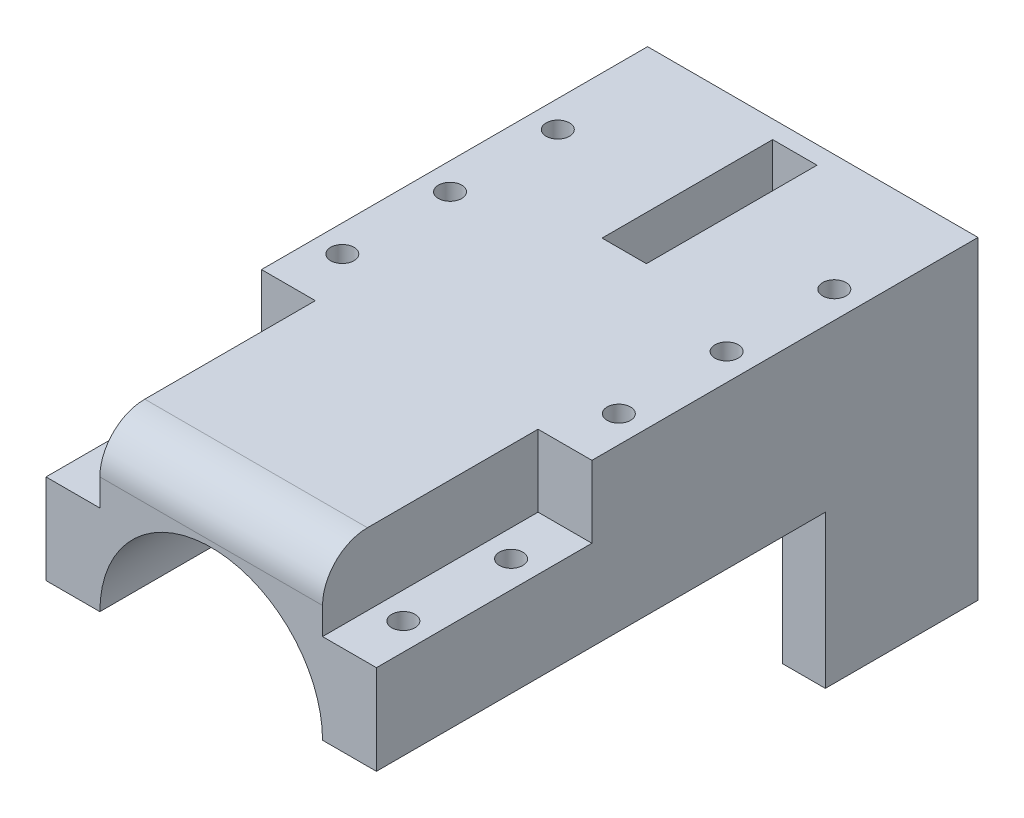
from build123d import *

# Parameters (mm, degrees)
BOSS_EXTRU_1_DEPTH       = 132
ESQUISSE3_W              = 4.94012132
ESQUISSE3_H              = 40
ENL_V_MAT_EXTRU_2_DEPTH  = 9
ESQUISSE4_R              = 1.3
ENL_V_MAT_EXTRU_3_DEPTH  = 18
ESQUISSE5_W              = 6
ESQUISSE5_H              = 24
ENL_V_MAT_EXTRU_4_DEPTH  = 8
BOSS_EXTRU_2_REACH       = 38.8
ESQUISSE7_W              = 2
ESQUISSE7_H              = 18
ENL_V_MAT_EXTRU_5_DEPTH  = 15
ENL_V_MAT_EXTRU_6_DEPTH  = 15
ESQUISSE10_W             = 5.625
ESQUISSE10_H             = 32
BOSS_EXTRU_3_DEPTH       = 17
ESQUISSE14_W             = 11.349962924
ESQUISSE14_H             = 7.588006138
BOSS_EXTRU_5_DEPTH       = 6
ESQUISSE16_W             = 13.258712606
ESQUISSE16_H             = 4.272246905
ENL_V_MAT_EXTRU_7_DEPTH  = 11
ESQUISSE17_W             = 15.613345165
ESQUISSE17_H             = 5.100882875
BOSS_EXTRU_6_DEPTH       = 11
BOSS_EXTRU_6_DEPTH_BACK  = 11
ESQUISSE11_R             = 1.85
ESQUISSE11_R_2           = 1.3
ESQUISSE11_R_3           = 2.916438904
ENL_V_MAT_EXTRU_8_DEPTH  = 8
ESQUISSE18_W             = 9.677736186
ESQUISSE18_H             = 8.253244783
ENL_V_MAT_EXTRU_9_DEPTH  = 10
CONG_2_R                 = 5
ESQUISSE20_W             = 27.3
ESQUISSE20_H             = 40.032665724
ENL_V_MAT_EXTRU_11_DEPTH = 22
ESQUISSE22_R             = 2.780350547
ENL_V_MAT_EXTRU_12_DEPTH = 33
ENL_V_MAT_EXTRU_13_DEPTH = 23
ESQUISSE24_W             = 101.568694303
ESQUISSE24_H             = 64.896510992
ENL_V_MAT_EXTRU_14_DEPTH = 80


with BuildPart() as part:
    # Esquisse1 → Boss.-Extru.1 (new body)
    with BuildSketch(Plane.XY):
        with BuildLine():
            Line((-12.4, 0), (-18.4, 0))
            Line((-18.4, 0), (-18.4, 18))
            Line((-18.4, 18), (18.4, 18))
            Line((18.4, 18), (18.4, 0))
            Line((18.4, 0), (12.4, 0))
            ThreePointArc((12.4, 0), (0, 12.4), (-12.4, 0))
        make_face()
    extrude(amount=BOSS_EXTRU_1_DEPTH)

    # Esquisse3 → Enlèv. mat.-Extru.2 (cut)
    with BuildSketch(Plane.XZ.offset(-18)):
        with Locations((0, 66)):
            Rectangle(ESQUISSE3_W, ESQUISSE3_H)
    extrude(amount=ENL_V_MAT_EXTRU_2_DEPTH, mode=Mode.SUBTRACT)

    # Esquisse4 → Enlèv. mat.-Extru.3 (cut)
    with BuildSketch(Plane(origin=(0, 18, 0), x_dir=(1, 0, 0), z_dir=(0, 1, 0))):
        with Locations((15.4, -6)):
            Circle(ESQUISSE4_R)
        with Locations((15.4, -18)):
            Circle(ESQUISSE4_R)
        with Locations((-15.4, -6)):
            Circle(ESQUISSE4_R)
        with Locations((-15.4, -18)):
            Circle(ESQUISSE4_R)
        with Locations((15.4, -30)):
            Circle(ESQUISSE4_R)
        with Locations((-15.4, -30)):
            Circle(ESQUISSE4_R)
        with Locations((15.4, -42)):
            Circle(ESQUISSE4_R)
        with Locations((-15.4, -42)):
            Circle(ESQUISSE4_R)
        with Locations((-15.4, -126)):
            Circle(ESQUISSE4_R)
        with Locations((-15.4, -114)):
            Circle(ESQUISSE4_R)
        with Locations((-15.4, -102)):
            Circle(ESQUISSE4_R)
        with Locations((-15.4, -90)):
            Circle(ESQUISSE4_R)
        with Locations((-15.4, -78)):
            Circle(ESQUISSE4_R)
        with Locations((15.4, -78)):
            Circle(ESQUISSE4_R)
        with Locations((15.4, -90)):
            Circle(ESQUISSE4_R)
        with Locations((15.4, -102)):
            Circle(ESQUISSE4_R)
        with Locations((15.4, -114)):
            Circle(ESQUISSE4_R)
        with Locations((15.4, -126)):
            Circle(ESQUISSE4_R)
    extrude(amount=-ENL_V_MAT_EXTRU_3_DEPTH, mode=Mode.SUBTRACT)

    # Esquisse5 → Enlèv. mat.-Extru.4 (cut)
    with BuildSketch(Plane(origin=(0, 18, 0), x_dir=(1, 0, 0), z_dir=(0, 1, 0))):
        with Locations((15.4, -12)):
            Rectangle(ESQUISSE5_W, ESQUISSE5_H)
        with Locations((-15.4, -120)):
            Rectangle(ESQUISSE5_W, ESQUISSE5_H)
        with Locations((-15.4, -12)):
            Rectangle(ESQUISSE5_W, ESQUISSE5_H)
        with Locations((15.4, -120)):
            Rectangle(ESQUISSE5_W, ESQUISSE5_H)
    extrude(amount=-ENL_V_MAT_EXTRU_4_DEPTH, mode=Mode.SUBTRACT)

    # Esquisse7 → Boss.-Extru.2 (add, up to next)
    with BuildSketch(Plane.ZY.offset(18.4), mode=Mode.PRIVATE) as boss_extru_2_sk1:
        with Locations((66, 9)):
            Rectangle(ESQUISSE7_W, ESQUISSE7_H)
    boss_extru_2_tool1 = extrude(boss_extru_2_sk1.sketch, amount=-BOSS_EXTRU_2_REACH, mode=Mode.PRIVATE) - part.part
    add(boss_extru_2_tool1.solids().sort_by_distance((-18.4, 9, 66))[0])

    # Esquisse8 → Enlèv. mat.-Extru.5 (cut)
    with BuildSketch(Plane(origin=(0, 0, 65), x_dir=(-1, 0, 0), z_dir=(0, 0, -1))):
        with BuildLine():
            Line((12.775, 0), (-12.775, 0))
            ThreePointArc((-12.775, 0), (0, 12.775), (12.775, 0))
        make_face()
    extrude(amount=ENL_V_MAT_EXTRU_5_DEPTH, mode=Mode.SUBTRACT)

    # Esquisse9 → Enlèv. mat.-Extru.6 (cut)
    with BuildSketch(Plane.XY.offset(67)):
        with BuildLine():
            Line((12.775, 0), (-12.775, 0))
            ThreePointArc((-12.775, 0), (0, 12.775), (12.775, 0))
        make_face()
    extrude(amount=ENL_V_MAT_EXTRU_6_DEPTH, mode=Mode.SUBTRACT)

    # Esquisse10 → Boss.-Extru.3 (add)
    with BuildSketch(Plane.XZ):
        with Locations((15.5875, 66)):
            Rectangle(ESQUISSE10_W, ESQUISSE10_H)
        with Locations((-15.5875, 66)):
            Rectangle(ESQUISSE10_W, ESQUISSE10_H)
    extrude(amount=BOSS_EXTRU_3_DEPTH)

    # Esquisse14 → Boss.-Extru.5 (add)
    with BuildSketch(Plane(origin=(18.4, 0, 0), x_dir=(0, 0, -1), z_dir=(1, 0, 0))):
        with Locations((-50.7944077, 14.205996931)):
            Rectangle(ESQUISSE14_W, ESQUISSE14_H)
    extrude(amount=BOSS_EXTRU_5_DEPTH)

    # Esquisse16 → Enlèv. mat.-Extru.7 (cut)
    with BuildSketch(Plane(origin=(24.4, 0, 0), x_dir=(0, 0, -1), z_dir=(1, 0, 0))):
        with Locations((-50.566594151, 10.91391733)):
            Rectangle(ESQUISSE16_W, ESQUISSE16_H)
    extrude(amount=-ENL_V_MAT_EXTRU_7_DEPTH, mode=Mode.SUBTRACT)

    # Esquisse17 → Boss.-Extru.6 (add, two sides)
    with BuildSketch(Plane(origin=(18.4, 0, 0), x_dir=(0, 0, -1), z_dir=(1, 0, 0))) as boss_extru_6_sk:
        with Locations((-21.308135783, 15.449558563)):
            Rectangle(ESQUISSE17_W, ESQUISSE17_H)
    extrude(amount=BOSS_EXTRU_6_DEPTH)
    extrude(boss_extru_6_sk.sketch, amount=-BOSS_EXTRU_6_DEPTH_BACK)

    # Esquisse11 → Enlèv. mat.-Extru.8 (cut)
    with BuildSketch(Plane(origin=(0, 18, 0), x_dir=(1, 0, 0), z_dir=(0, 1, 0))):
        with Locations((24.22, -102)):
            Circle(ESQUISSE11_R)
        with Locations((19.13, -51)):
            Circle(ESQUISSE11_R)
        with Locations((24.22, -20.6)):
            Circle(ESQUISSE11_R)
        with Locations((-8.37, -51)):
            Circle(ESQUISSE11_R)
        with Locations((15.4, -6)):
            Circle(ESQUISSE11_R_2)
        with Locations((15.4, -18)):
            Circle(ESQUISSE11_R_3)
        with Locations((-23.98, -101)):
            Circle(ESQUISSE11_R)
        with Locations((-23.98, -28)):
            Circle(ESQUISSE11_R)
    extrude(amount=-ENL_V_MAT_EXTRU_8_DEPTH, mode=Mode.SUBTRACT)

    # Esquisse18 → Enlèv. mat.-Extru.9 (cut)
    with BuildSketch(Plane(origin=(-2.47006066, 0, 0), x_dir=(0, 0, -1), z_dir=(1, 0, 0))):
        with Locations((-50.900131157, 9.01339788)):
            Rectangle(ESQUISSE18_W, ESQUISSE18_H)
    extrude(amount=-ENL_V_MAT_EXTRU_9_DEPTH, mode=Mode.SUBTRACT)

    # Congé2
    cong_2_edges = [part.edges().sort_by_distance(p)[0] for p in [
        (0, 18, 0),
        (0, 18, 132),
    ]]
    fillet(cong_2_edges, radius=CONG_2_R)

    # Esquisse20 → Enlèv. mat.-Extru.11 (cut)
    with BuildSketch(Plane.XZ):
        with Locations((0, 66)):
            Rectangle(ESQUISSE20_W, ESQUISSE20_H)
    extrude(amount=ENL_V_MAT_EXTRU_11_DEPTH, mode=Mode.SUBTRACT)

    # Esquisse22 → Enlèv. mat.-Extru.12 (cut)
    with BuildSketch(Plane.XZ.offset(-13.050040782)):
        with Locations((19.13, 51)):
            Circle(ESQUISSE22_R)
    extrude(amount=ENL_V_MAT_EXTRU_12_DEPTH, mode=Mode.SUBTRACT)

    # Esquisse23 → Enlèv. mat.-Extru.13 (cut)
    with BuildSketch(Plane.XZ.offset(-13.140020271)):
        Polygon((-10.962659815, 54.736061467), (-30.574521602, 60.209177611), (-30.574521602, 54.651975737), (-10.962659815, 50.396101529), align=None)
    extrude(amount=ENL_V_MAT_EXTRU_13_DEPTH, mode=Mode.SUBTRACT)

    # Esquisse24 → Enlèv. mat.-Extru.14 (cut)
    with BuildSketch(Plane(origin=(0, 0, 65), x_dir=(-1, 0, 0), z_dir=(0, 0, -1))):
        with Locations((-4.820186709, 5.897951476)):
            Rectangle(ESQUISSE24_W, ESQUISSE24_H)
    extrude(amount=ENL_V_MAT_EXTRU_14_DEPTH, mode=Mode.SUBTRACT)


solid = part.part
